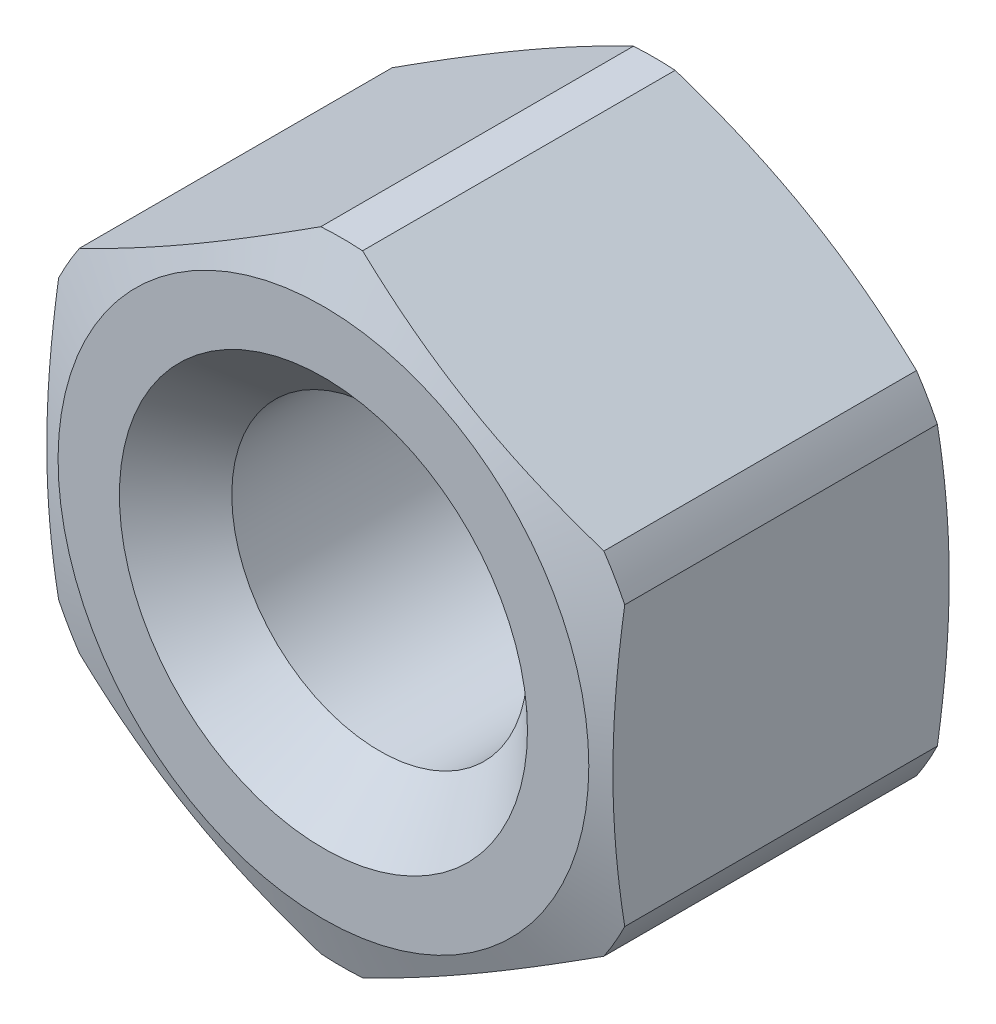
from build123d import *

# Parameters (mm, degrees)
SKETCH_2_OUTSIDE_W  = 36.874
SKETCH_2_OUTSIDE_H  = 36.874
CUT_EXTRUDE_1_DEPTH = 15.8


with BuildPart() as part:
    # Эскиз1 → Повернуть1 (revolve)
    with BuildSketch(Plane(origin=(0, 0, 0), x_dir=(0, 0, -1), z_dir=(1, 0, 0))):
        Polygon((-5.017949192, 6.267949192), (5.017949192, 6.267949192), (7.4, 8.65), (7.4, 11.25), (6.626563252, 13.375), (-6.626563252, 13.375), (-7.4, 11.25), (-7.4, 8.65), align=None)
    revolve(axis=Axis((0, 0, 152.740188543), (0, 0, -1)))

    # Эскиз2 outside → Вырез-Вытянуть1 (cut, through all)
    with BuildSketch(Plane.XY.offset(7.4)):
        Rectangle(SKETCH_2_OUTSIDE_W, SKETCH_2_OUTSIDE_H)
        Polygon((0, -13.856406461), (12, -6.92820323), (12, 6.92820323), (0, 13.856406461), (-12, 6.92820323), (-12, -6.92820323), align=None, mode=Mode.SUBTRACT)
    extrude(amount=-CUT_EXTRUDE_1_DEPTH, mode=Mode.SUBTRACT)


solid = part.part
